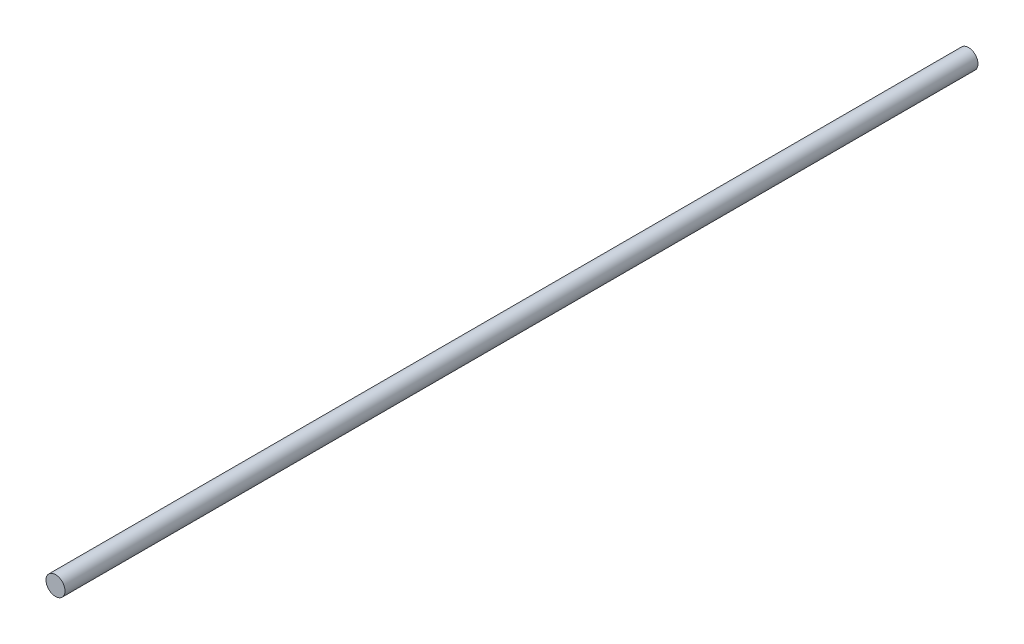
from build123d import *

# Parameters (mm, degrees)
SKETCH1_R           = 3.175
BOSS_EXTRUDE1_DEPTH = 152.4


with BuildPart() as part:
    # Sketch1 → Boss-Extrude1 (new body, symmetric)
    with BuildSketch(Plane.XY):
        Circle(SKETCH1_R)
    extrude(amount=BOSS_EXTRUDE1_DEPTH, both=True)


solid = part.part
